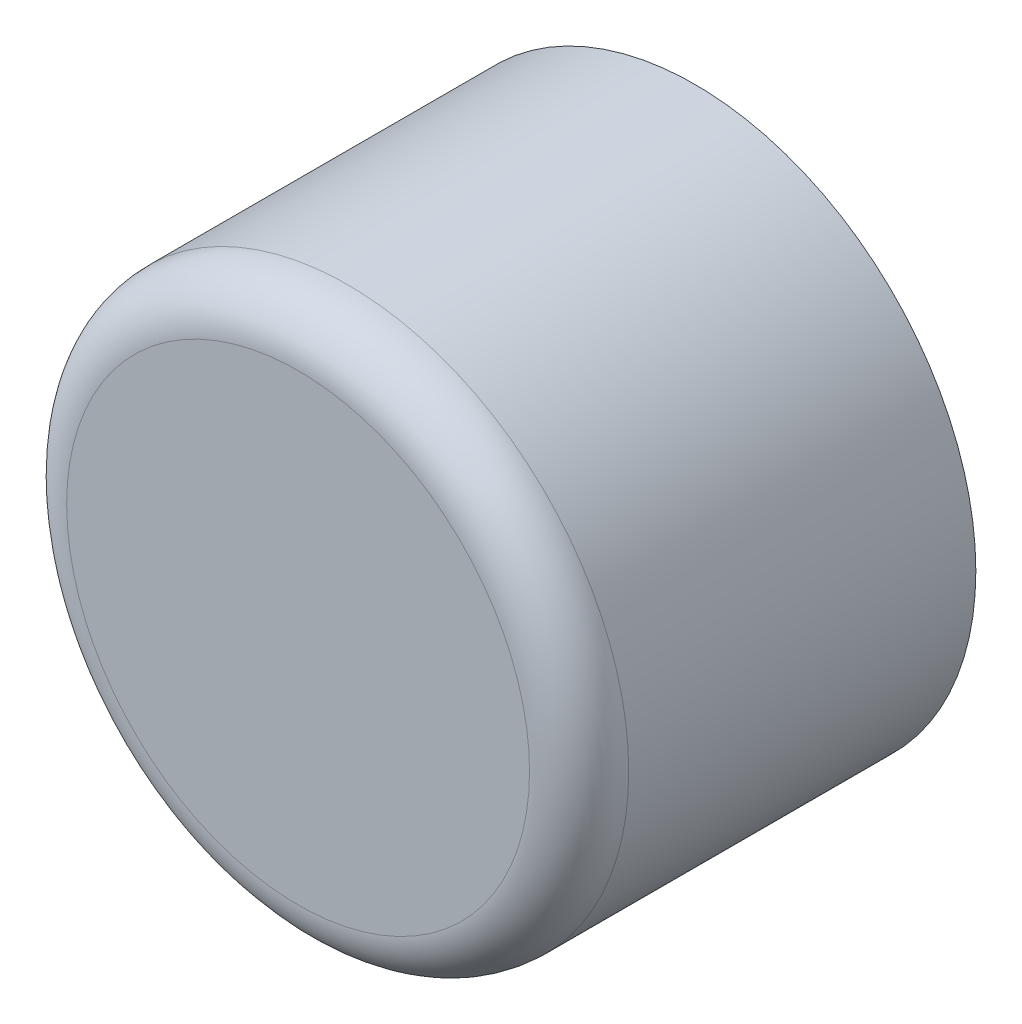
from build123d import *

# Parameters (mm, degrees)
SKETCH_1_R      = 8.5
EXTRUDE_1_DEPTH = 12
FILLET_1_R      = 1.5


with BuildPart() as part:
    # Эскиз1 → Бобышка-Вытянуть1 (new body)
    with BuildSketch(Plane.XY):
        Circle(SKETCH_1_R)
    extrude(amount=EXTRUDE_1_DEPTH)

    # Скругление1
    fillet_1_edges = [part.edges().sort_by_distance(p)[0] for p in [
        (-8.5, 0, 12),
    ]]
    fillet(fillet_1_edges, radius=FILLET_1_R)


solid = part.part
